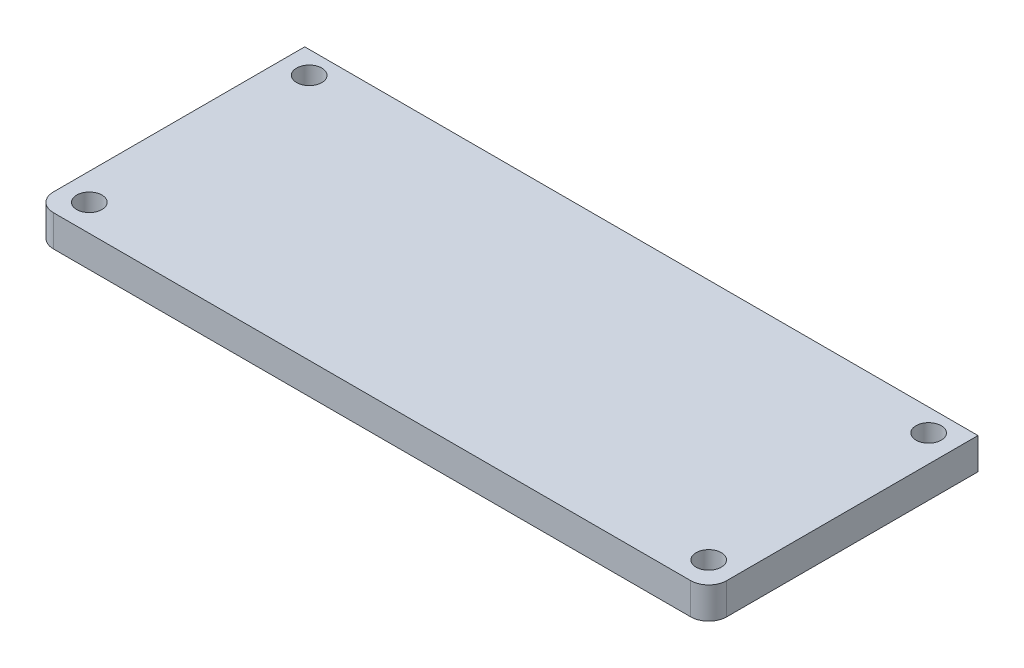
from build123d import *

# Parameters (mm, degrees)
SKETCH1_W                   = 190.5
SKETCH1_H                   = 76.2
BOSS_EXTRUDE1_DEPTH         = 8.89
F_1_4_CLEARANCE_HOLE1_D     = 7.14248
F_1_4_CLEARANCE_HOLE1_DEPTH = 8.89
FILLET1_R                   = 5.08


with BuildPart() as part:
    # Sketch1 → Boss-Extrude1 (new body)
    with BuildSketch(Plane(origin=(0, 0, 0), x_dir=(1, 0, 0), z_dir=(0, 1, 0))):
        Rectangle(SKETCH1_W, SKETCH1_H)
    extrude(amount=BOSS_EXTRUDE1_DEPTH)

    # 1/4 Clearance Hole1
    with Locations(Plane(origin=(0, 8.89, 0), x_dir=(-1, 0, 0), z_dir=(0, 1, 0))):
        with Locations((87.63, -31.75), (-87.63, -31.75), (-87.63, 30.48), (87.63, 30.48)):
            Hole(F_1_4_CLEARANCE_HOLE1_D / 2, depth=F_1_4_CLEARANCE_HOLE1_DEPTH)

    # Fillet1
    fillet1_edges = [part.edges().sort_by_distance(p)[0] for p in [
        (95.25, 4.445, 38.1),
        (-95.25, 4.445, 38.1),
    ]]
    fillet(fillet1_edges, radius=FILLET1_R)


solid = part.part
